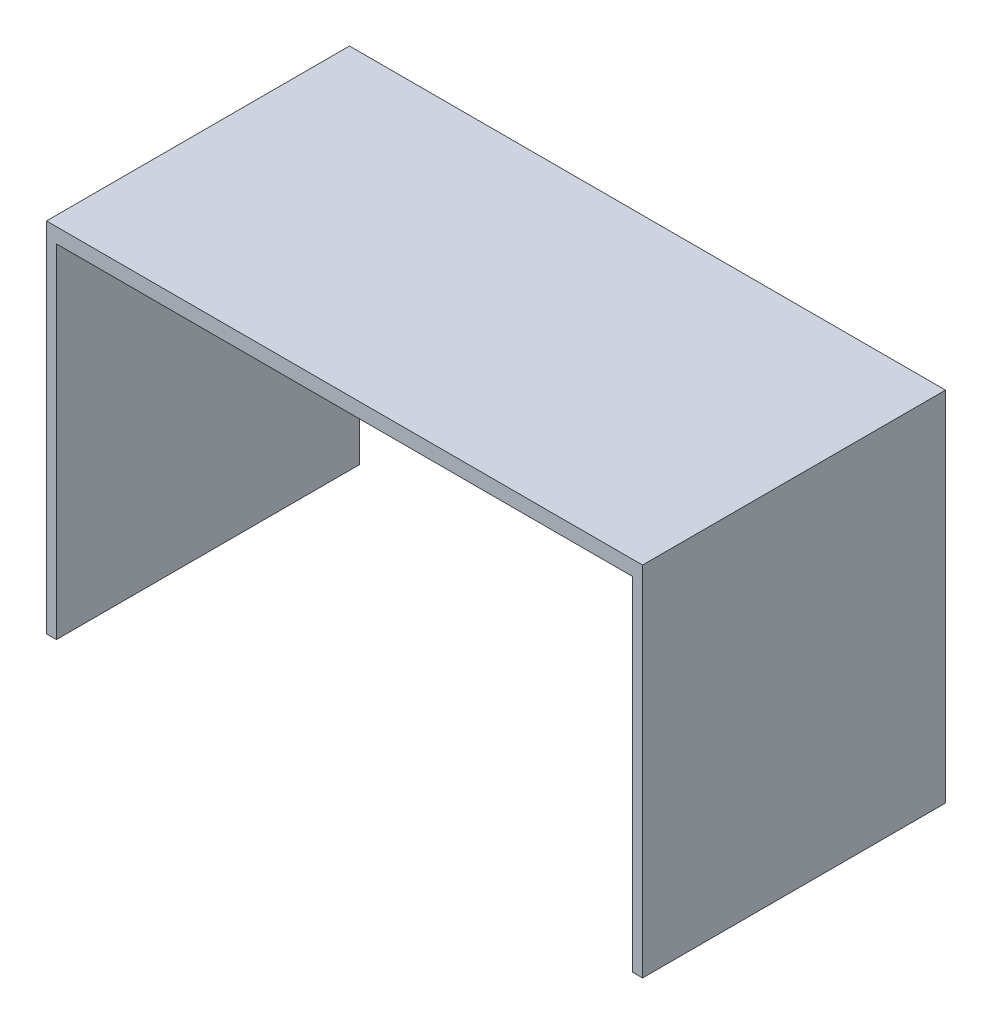
from build123d import *

# Parameters (mm, degrees)
SKETCH1_W           = 1524
SKETCH1_H           = 774.7
BOSS_EXTRUDE1_DEPTH = 914.4
SKETCH2_W           = 1473.2
SKETCH2_H           = 876.3
CUT_EXTRUDE1_DEPTH  = 889


with BuildPart() as part:
    # Sketch1 → Boss-Extrude1 (new body)
    with BuildSketch(Plane(origin=(0, 0, 0), x_dir=(1, 0, 0), z_dir=(0, 1, 0))):
        Rectangle(SKETCH1_W, SKETCH1_H)
    extrude(amount=BOSS_EXTRUDE1_DEPTH)

    # Sketch2 → Cut-Extrude1 (cut)
    with BuildSketch(Plane.XY.offset(387.35)):
        with Locations((0, 438.15)):
            Rectangle(SKETCH2_W, SKETCH2_H)
    extrude(amount=-CUT_EXTRUDE1_DEPTH, mode=Mode.SUBTRACT)


solid = part.part
